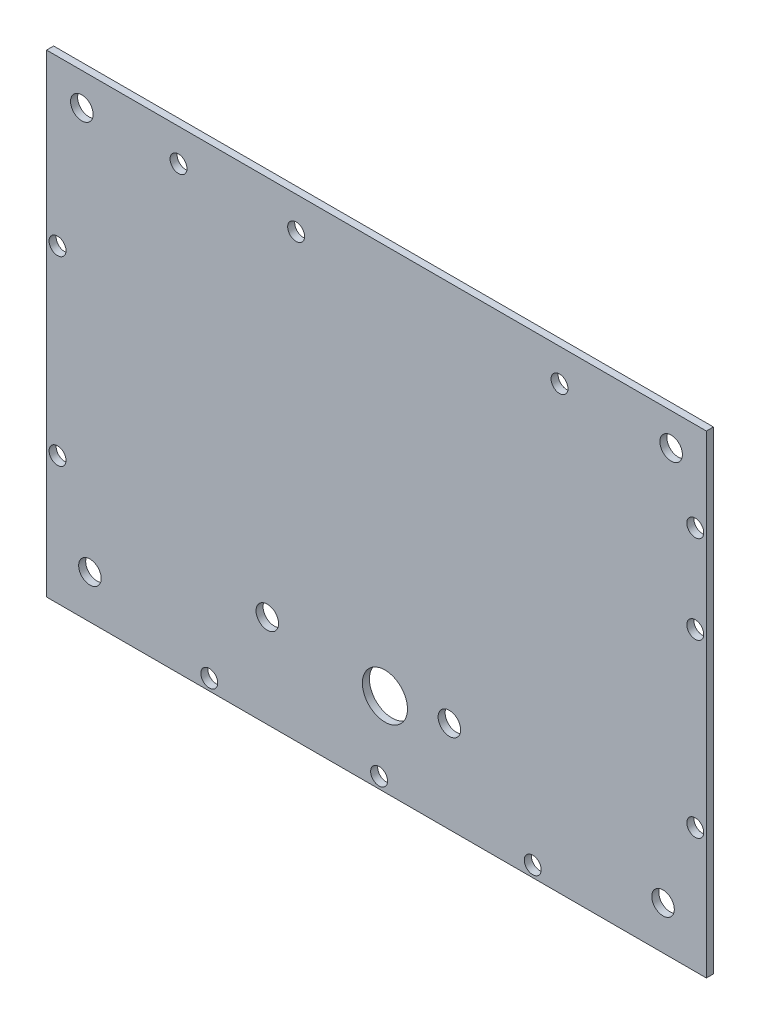
from build123d import *

# Parameters (mm, degrees)
SKETCH1_W           = 148.59
SKETCH1_H           = 106.68
BOSS_EXTRUDE1_DEPTH = 1.5875
SKETCH2_R           = 2.54
CUT_EXTRUDE1_DEPTH  = 2.5875
CUT_EXTRUDE2_REACH  = 3.587
SKETCH3_R           = 5.08
CUT_EXTRUDE3_REACH  = 3.587
SKETCH4_R           = 1.905
CUT_EXTRUDE4_REACH  = 3.587
SKETCH5_R           = 2.54


with BuildPart() as part:
    # Sketch1 → Boss-Extrude1 (new body)
    with BuildSketch(Plane.XY):
        Rectangle(SKETCH1_W, SKETCH1_H)
    extrude(amount=BOSS_EXTRUDE1_DEPTH)

    # Sketch2 → Cut-Extrude1 (cut, through all)
    with BuildSketch(Plane.XY.offset(1.5875)):
        with Locations((-64.5325, -43.5775)):
            Circle(SKETCH2_R)
        with Locations((64.5325, -43.5775)):
            Circle(SKETCH2_R)
        with Locations((-66.3575, 46.0375)):
            Circle(SKETCH2_R)
        with Locations((66.3575, 46.0375)):
            Circle(SKETCH2_R)
    extrude(amount=-CUT_EXTRUDE1_DEPTH, mode=Mode.SUBTRACT)

    # Sketch3 → Cut-Extrude2 (cut, up to next)
    with BuildSketch(Plane.XY.offset(1.5875), mode=Mode.PRIVATE) as cut_extrude2_sk1:
        with Locations((1.905, -34.544)):
            Circle(SKETCH3_R)
    cut_extrude2_tool1 = extrude(cut_extrude2_sk1.sketch, amount=-CUT_EXTRUDE2_REACH, mode=Mode.PRIVATE) & part.part
    add(cut_extrude2_tool1.solids().sort_by_distance((1.905, -34.544, 1.5875))[0], mode=Mode.SUBTRACT)

    # Sketch4 → Cut-Extrude3 (cut, up to next)
    with BuildSketch(Plane.XY.offset(1.5875), mode=Mode.PRIVATE) as cut_extrude3_sk1:
        with Locations((-44.578582342, 46.016934616)):
            Circle(SKETCH4_R)
    cut_extrude3_tool1 = extrude(cut_extrude3_sk1.sketch, amount=-CUT_EXTRUDE3_REACH, mode=Mode.PRIVATE) & part.part
    add(cut_extrude3_tool1.solids().sort_by_distance((-44.578582, 46.016935, 1.5875))[0], mode=Mode.SUBTRACT)
    # Sketch4 → Cut-Extrude3 (cut, up to next)
    with BuildSketch(Plane.XY.offset(1.5875), mode=Mode.PRIVATE) as cut_extrude3_sk2:
        with Locations((-18.096274256, 46.016934616)):
            Circle(SKETCH4_R)
    cut_extrude3_tool2 = extrude(cut_extrude3_sk2.sketch, amount=-CUT_EXTRUDE3_REACH, mode=Mode.PRIVATE) & part.part
    add(cut_extrude3_tool2.solids().sort_by_distance((-18.096274, 46.016935, 1.5875))[0], mode=Mode.SUBTRACT)
    # Sketch4 → Cut-Extrude3 (cut, up to next)
    with BuildSketch(Plane.XY.offset(1.5875), mode=Mode.PRIVATE) as cut_extrude3_sk3:
        with Locations((41.222617745, 46.016934616)):
            Circle(SKETCH4_R)
    cut_extrude3_tool3 = extrude(cut_extrude3_sk3.sketch, amount=-CUT_EXTRUDE3_REACH, mode=Mode.PRIVATE) & part.part
    add(cut_extrude3_tool3.solids().sort_by_distance((41.222618, 46.016935, 1.5875))[0], mode=Mode.SUBTRACT)
    # Sketch4 → Cut-Extrude3 (cut, up to next)
    with BuildSketch(Plane.XY.offset(1.5875), mode=Mode.PRIVATE) as cut_extrude3_sk4:
        with Locations((71.795, 33.199680415)):
            Circle(SKETCH4_R)
    cut_extrude3_tool4 = extrude(cut_extrude3_sk4.sketch, amount=-CUT_EXTRUDE3_REACH, mode=Mode.PRIVATE) & part.part
    add(cut_extrude3_tool4.solids().sort_by_distance((71.795, 33.19968, 1.5875))[0], mode=Mode.SUBTRACT)
    # Sketch4 → Cut-Extrude3 (cut, up to next)
    with BuildSketch(Plane.XY.offset(1.5875), mode=Mode.PRIVATE) as cut_extrude3_sk5:
        with Locations((71.795, 13.37524336)):
            Circle(SKETCH4_R)
    cut_extrude3_tool5 = extrude(cut_extrude3_sk5.sketch, amount=-CUT_EXTRUDE3_REACH, mode=Mode.PRIVATE) & part.part
    add(cut_extrude3_tool5.solids().sort_by_distance((71.795, 13.375243, 1.5875))[0], mode=Mode.SUBTRACT)
    # Sketch4 → Cut-Extrude3 (cut, up to next)
    with BuildSketch(Plane.XY.offset(1.5875), mode=Mode.PRIVATE) as cut_extrude3_sk6:
        with Locations((71.795, -25.245906802)):
            Circle(SKETCH4_R)
    cut_extrude3_tool6 = extrude(cut_extrude3_sk6.sketch, amount=-CUT_EXTRUDE3_REACH, mode=Mode.PRIVATE) & part.part
    add(cut_extrude3_tool6.solids().sort_by_distance((71.795, -25.245907, 1.5875))[0], mode=Mode.SUBTRACT)
    # Sketch4 → Cut-Extrude3 (cut, up to next)
    with BuildSketch(Plane.XY.offset(1.5875), mode=Mode.PRIVATE) as cut_extrude3_sk7:
        with Locations((35.197381877, -50.84)):
            Circle(SKETCH4_R)
    cut_extrude3_tool7 = extrude(cut_extrude3_sk7.sketch, amount=-CUT_EXTRUDE3_REACH, mode=Mode.PRIVATE) & part.part
    add(cut_extrude3_tool7.solids().sort_by_distance((35.197382, -50.84, 1.5875))[0], mode=Mode.SUBTRACT)
    # Sketch4 → Cut-Extrude3 (cut, up to next)
    with BuildSketch(Plane.XY.offset(1.5875), mode=Mode.PRIVATE) as cut_extrude3_sk8:
        with Locations((0.59225822, -50.84)):
            Circle(SKETCH4_R)
    cut_extrude3_tool8 = extrude(cut_extrude3_sk8.sketch, amount=-CUT_EXTRUDE3_REACH, mode=Mode.PRIVATE) & part.part
    add(cut_extrude3_tool8.solids().sort_by_distance((0.592258, -50.84, 1.5875))[0], mode=Mode.SUBTRACT)
    # Sketch4 → Cut-Extrude3 (cut, up to next)
    with BuildSketch(Plane.XY.offset(1.5875), mode=Mode.PRIVATE) as cut_extrude3_sk9:
        with Locations((-37.65546217, -50.84)):
            Circle(SKETCH4_R)
    cut_extrude3_tool9 = extrude(cut_extrude3_sk9.sketch, amount=-CUT_EXTRUDE3_REACH, mode=Mode.PRIVATE) & part.part
    add(cut_extrude3_tool9.solids().sort_by_distance((-37.655462, -50.84, 1.5875))[0], mode=Mode.SUBTRACT)
    # Sketch4 → Cut-Extrude3 (cut, up to next)
    with BuildSketch(Plane.XY.offset(1.5875), mode=Mode.PRIVATE) as cut_extrude3_sk10:
        with Locations((-71.823750006, -24.517485795)):
            Circle(SKETCH4_R)
    cut_extrude3_tool10 = extrude(cut_extrude3_sk10.sketch, amount=-CUT_EXTRUDE3_REACH, mode=Mode.PRIVATE) & part.part
    add(cut_extrude3_tool10.solids().sort_by_distance((-71.82375, -24.517486, 1.5875))[0], mode=Mode.SUBTRACT)
    # Sketch4 → Cut-Extrude3 (cut, up to next)
    with BuildSketch(Plane.XY.offset(1.5875), mode=Mode.PRIVATE) as cut_extrude3_sk11:
        with Locations((-71.823750006, 16.385688775)):
            Circle(SKETCH4_R)
    cut_extrude3_tool11 = extrude(cut_extrude3_sk11.sketch, amount=-CUT_EXTRUDE3_REACH, mode=Mode.PRIVATE) & part.part
    add(cut_extrude3_tool11.solids().sort_by_distance((-71.82375, 16.385689, 1.5875))[0], mode=Mode.SUBTRACT)

    # Sketch5 → Cut-Extrude4 (cut, up to next)
    with BuildSketch(Plane.XY.offset(1.5875), mode=Mode.PRIVATE) as cut_extrude4_sk1:
        with Locations((-24.584832927, -32.40931441)):
            Circle(SKETCH5_R)
    cut_extrude4_tool1 = extrude(cut_extrude4_sk1.sketch, amount=-CUT_EXTRUDE4_REACH, mode=Mode.PRIVATE) & part.part
    add(cut_extrude4_tool1.solids().sort_by_distance((-24.584833, -32.409314, 1.5875))[0], mode=Mode.SUBTRACT)
    # Sketch5 → Cut-Extrude4 (cut, up to next)
    with BuildSketch(Plane.XY.offset(1.5875), mode=Mode.PRIVATE) as cut_extrude4_sk2:
        with Locations((16.415053576, -32.617647841)):
            Circle(SKETCH5_R)
    cut_extrude4_tool2 = extrude(cut_extrude4_sk2.sketch, amount=-CUT_EXTRUDE4_REACH, mode=Mode.PRIVATE) & part.part
    add(cut_extrude4_tool2.solids().sort_by_distance((16.415054, -32.617648, 1.5875))[0], mode=Mode.SUBTRACT)


solid = part.part
